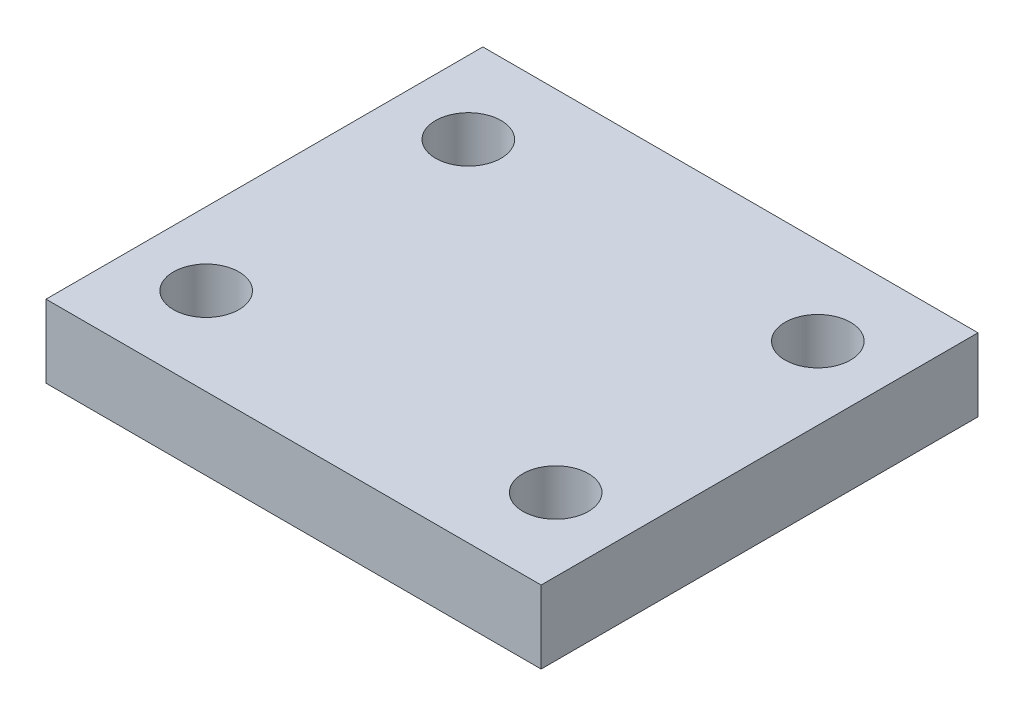
from build123d import *

# Parameters (mm, degrees)
SKETCH1_W           = 34
SKETCH1_H           = 30
SKETCH1_R           = 2.25
BOSS_EXTRUDE1_DEPTH = 5


with BuildPart() as part:
    # Sketch1 → Boss-Extrude1 (new body)
    with BuildSketch(Plane(origin=(0, 0, 0), x_dir=(1, 0, 0), z_dir=(0, 1, 0))):
        with Locations((17, 15)):
            Rectangle(SKETCH1_W, SKETCH1_H)
        with Locations((5, 6)):
            Circle(SKETCH1_R, mode=Mode.SUBTRACT)
        with Locations((29, 6)):
            Circle(SKETCH1_R, mode=Mode.SUBTRACT)
        with Locations((29, 24)):
            Circle(SKETCH1_R, mode=Mode.SUBTRACT)
        with Locations((5, 24)):
            Circle(SKETCH1_R, mode=Mode.SUBTRACT)
    extrude(amount=BOSS_EXTRUDE1_DEPTH)


solid = part.part
